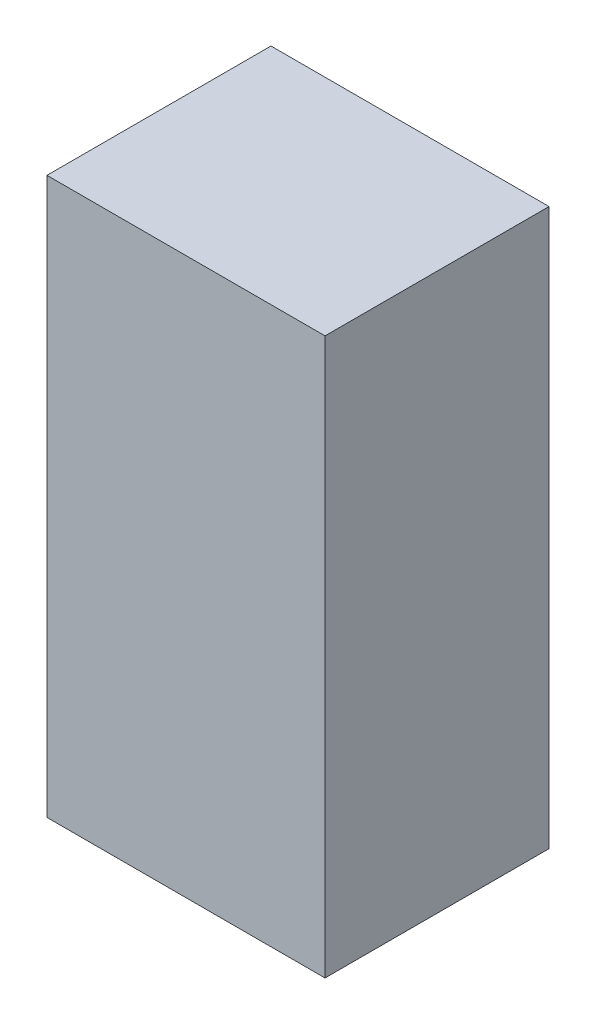
from build123d import *

# Parameters (mm, degrees)
SKETCH1_W           = 36
SKETCH1_H           = 29
BOSS_EXTRUDE1_DEPTH = 72


with BuildPart() as part:
    # Sketch1 → Boss-Extrude1 (new body)
    with BuildSketch(Plane(origin=(0, 0, 0), x_dir=(1, 0, 0), z_dir=(0, 1, 0))):
        Rectangle(SKETCH1_W, SKETCH1_H)
    extrude(amount=BOSS_EXTRUDE1_DEPTH)


solid = part.part
